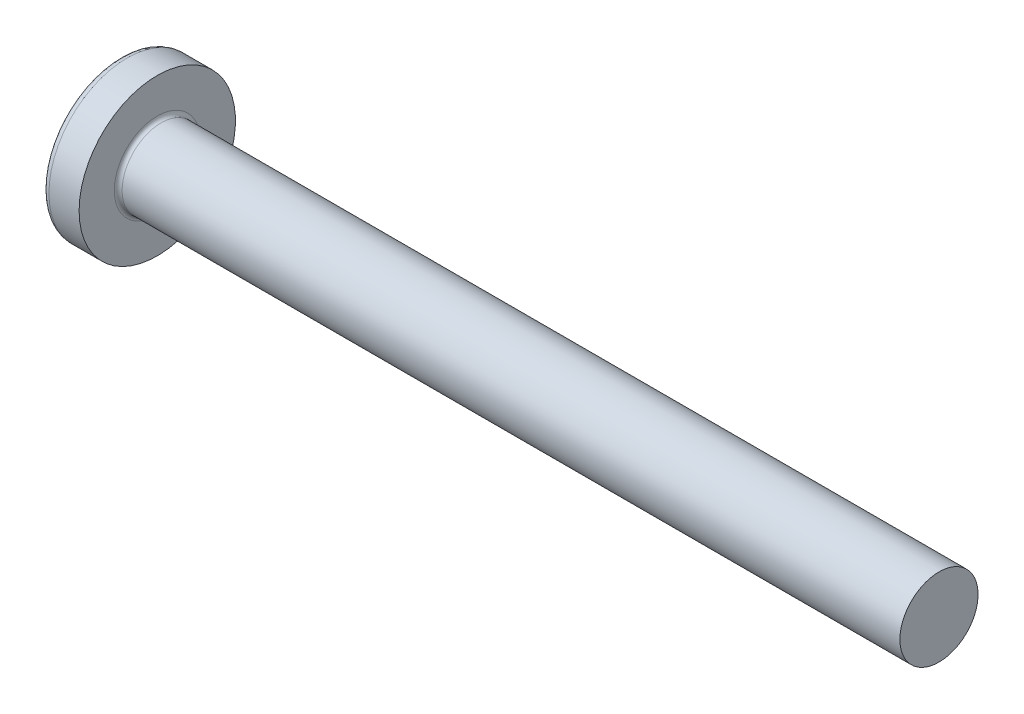
from build123d import *

# Parameters (mm, degrees)
FILLET1_R    = 0.2
SKETCH3_W    = 1.03
SKETCH3_H    = 4.3
SKETCH4_W    = 1.03
SKETCH4_H    = 1.966638464
RECPAT_COUNT = 2
RECPAT_ANGLE = 90


with BuildPart() as part:
    # BodySke → Base-Revolve (revolve)
    with BuildSketch(Plane.XY):
        with BuildLine():
            Line((3.1, 2), (3.1, 4))
            Line((3.1, 4), (1.555305874, 4))
            ThreePointArc((1.555305874, 4), (1.392873227, 3.961271902), (1.265388955, 3.853420195))
            ThreePointArc((1.265388955, 3.853420195), (0.324444487, 2.027933456), (0, 0))
            Line((0, 0), (43.1, 0))
            Line((43.1, 0), (43.1, 2))
            Line((43.1, 2), (3.1, 2))
        make_face()
    revolve(axis=Axis((-25.4, 0, 0), (1, 0, 0)))

    # Fillet1
    fillet1_edges = [part.edges().sort_by_distance(p)[0] for p in [
        (3.1, -2, 0),
    ]]
    fillet(fillet1_edges, radius=FILLET1_R)

    # Sketch3 → Recess section 0
    with BuildSketch(Plane(origin=(0, 0, 0), x_dir=(0, 0, -1), z_dir=(1, 0, 0))):
        Rectangle(SKETCH3_W, SKETCH3_H)
    # Sketch4 → Recess section 1
    with BuildSketch(Plane(origin=(2.34, 0, 0), x_dir=(0, 0, -1), z_dir=(1, 0, 0))):
        Rectangle(SKETCH4_W, SKETCH4_H)
    recess = loft(mode=Mode.SUBTRACT)

    # RecPat: Recess ×2 about axis
    recpat_axis = Axis((0, 0, 0), (1, 0, 0))
    for i in range(1, RECPAT_COUNT):
        add(recess.rotate(recpat_axis, i * RECPAT_ANGLE / (RECPAT_COUNT - 1)), mode=Mode.SUBTRACT)

    # RecCorSke → RecessCore (revolve, cut)
    with BuildSketch(Plane.XY):
        Polygon((0, 0), (0, 1.01462874), (2.34, 0.851), (2.616506661, 0), align=None)
    revolve(axis=Axis((-3.175, 0, 0), (1, 0, 0)), mode=Mode.SUBTRACT)


solid = part.part
